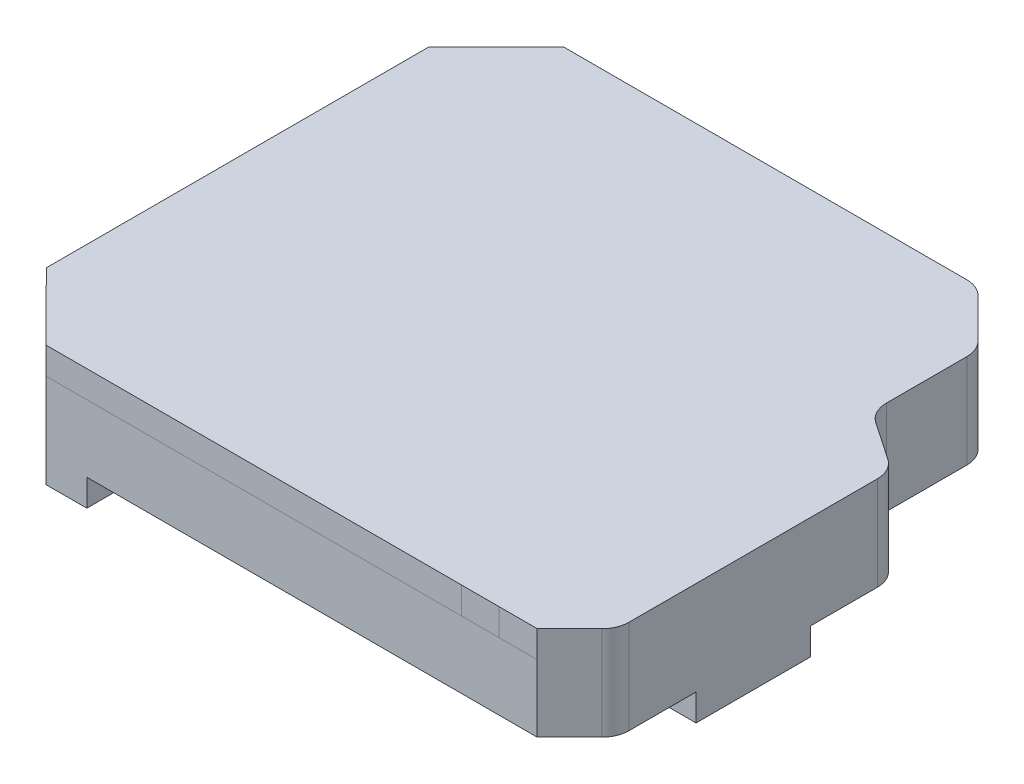
from build123d import *
from OCP.BRepFilletAPI import BRepFilletAPI_MakeChamfer

# Parameters (mm, degrees)
SKETCH1_W               = 41
SKETCH1_H               = 34.5
SKETCH1_W_2             = 35
SKETCH1_H_2             = 28.5
BOSS_EXTRUDE1_DEPTH     = 5
SKETCH2_W               = 35
SKETCH2_H               = 28.5
BOSS_EXTRUDE2_DEPTH     = 1
SKETCH6_W               = 34.5
SKETCH6_H               = 5
CUT_EXTRUDE2_DEPTH      = 3
SKETCH7_W               = 1.6
SKETCH7_H               = 3
SKETCH7_H_2             = 3.078736203
BOSS_EXTRUDE3_DEPTH     = 4
CHAMFER1_SIZE           = 3
SKETCH14_W              = 3.502632447
SKETCH14_H              = 20.452559449
CUT_EXTRUDE6_DEPTH      = 10
BOSS_EXTRUDE5_DEPTH     = 4
BOSS_EXTRUDE7_DEPTH     = 1
SKETCH9_W               = 3.28281374
SKETCH9_H               = 22.420706044
CUT_EXTRUDE3_DEPTH      = 4
BOSS_EXTRUDE4_DEPTH     = 2
SKETCH12_W              = 3.28281374
SKETCH12_H              = 22.420706044
CUT_EXTRUDE4_DEPTH      = 0.003863752
BOSS_EXTRUDE8_DEPTH     = 2
BOSS_EXTRUDE9_DEPTH     = 2
CUT_EXTRUDE7_DEPTH      = 38.864903937
CUT_EXTRUDE7_DEPTH_BACK = 4
CHAMFER2_SIZE           = 3
CHAMFER2_SIZE_2         = 3.001586398
CHAMFER2_SIZE2          = 3
CHAMFER3_SIZE           = 2
BOSS_EXTRUDE10_DEPTH    = 7
CUT_EXTRUDE8_START      = -2
CUT_EXTRUDE8_DEPTH      = 7
CUT_EXTRUDE9_DEPTH      = 7
CUT_EXTRUDE11_START     = 1
CUT_EXTRUDE11_DEPTH     = 10
CUT_EXTRUDE12_DEPTH     = 10
SKETCH30_W              = 2.837179027
SKETCH30_H              = 7
CUT_EXTRUDE13_DEPTH     = 10
BOSS_EXTRUDE11_DEPTH    = 7
CUT_EXTRUDE14_DEPTH     = 7
SKETCH35_W              = 36.645868519
SKETCH35_H              = 38.499838471
CUT_EXTRUDE15_DEPTH     = 2
SKETCH37_W              = 2
SKETCH37_H              = 8.507497338
BOSS_EXTRUDE12_DEPTH    = 2
FILLET2_R               = 2


with BuildPart() as part:
    # Sketch1 → Boss-Extrude1 (new body)
    with BuildSketch(Plane(origin=(0, 0, 0), x_dir=(1, 0, 0), z_dir=(0, 1, 0))):
        with Locations((-14.14154724, 0.334775681)):
            Rectangle(SKETCH1_W, SKETCH1_H)
        with Locations((-14.14154724, 0.334775681)):
            Rectangle(SKETCH1_W_2, SKETCH1_H_2, mode=Mode.SUBTRACT)
    extrude(amount=BOSS_EXTRUDE1_DEPTH)

    # Sketch2 → Boss-Extrude2 (add)
    with BuildSketch(Plane(origin=(0, 0, 0), x_dir=(1, 0, 0), z_dir=(0, 1, 0))):
        with Locations((-14.14154724, 0.334775681)):
            Rectangle(SKETCH2_W, SKETCH2_H)
    extrude(amount=BOSS_EXTRUDE2_DEPTH)

    # Sketch6 → Cut-Extrude2 (cut)
    with BuildSketch(Plane.ZY.offset(34.64154724)):
        with Locations((-0.334775681, 2.5)):
            Rectangle(SKETCH6_W, SKETCH6_H)
    extrude(amount=-CUT_EXTRUDE2_DEPTH, mode=Mode.SUBTRACT)

    # Sketch7 → Boss-Extrude3 (add)
    with BuildSketch(Plane(origin=(0, 1, 0), x_dir=(1, 0, 0), z_dir=(0, 1, 0))):
        with Locations((-30.84154724, 13.084775681)):
            Rectangle(SKETCH7_W, SKETCH7_H)
        with Locations((-30.84154724, -12.375856218)):
            Rectangle(SKETCH7_W, SKETCH7_H_2)
    extrude(amount=BOSS_EXTRUDE3_DEPTH)

    # Chamfer1
    chamfer1_edges = [part.edges().sort_by_distance(p)[0] for p in [
        (-31.64154724, 2.5, -17.584775681),
        (-31.64154724, 2.5, 16.915224319),
        (6.35845276, 2.5, -17.584775681),
        (6.35845276, 2.5, 16.915224319),
    ]]
    chamfer(chamfer1_edges, length=CHAMFER1_SIZE)

    # Sketch14 → Cut-Extrude6 (cut)
    with BuildSketch(Plane(origin=(0, 1, 0), x_dir=(1, 0, 0), z_dir=(0, 1, 0))):
        with Locations((5.109768984, -7.134544415)):
            Rectangle(SKETCH14_W, SKETCH14_H)
    extrude(amount=CUT_EXTRUDE6_DEPTH, mode=Mode.SUBTRACT)

    # Sketch17 → Boss-Extrude5 (add)
    with BuildSketch(Plane(origin=(0, 1, 0), x_dir=(1, 0, 0), z_dir=(0, 1, 0))):
        Polygon((3.35845276, 3.09173531), (7.910000942, 0), (7.910000942, -13.915224319), (3.35845276, -13.915224319), (3.35845276, -16.915224319), (10.910000942, -16.915224319), (10.910000942, 3.419581668), (3.35845276, 8.549130391), align=None)
    extrude(amount=BOSS_EXTRUDE5_DEPTH)

    # Sketch19 → Boss-Extrude7 (add)
    with BuildSketch(Plane.XZ):
        Polygon((3.35845276, 16.915224319), (10.910000942, 16.915224319), (10.910000942, -3.419581668), (6.35845276, -6.511316978), (6.35845276, 13.915224319), align=None)
    extrude(amount=-BOSS_EXTRUDE7_DEPTH)

    # Sketch9 → Cut-Extrude3 (cut)
    with BuildSketch(Plane(origin=(0, 1, 0), x_dir=(1, 0, 0), z_dir=(0, 1, 0))):
        with Locations((-30.00014037, 0.374422659)):
            Rectangle(SKETCH9_W, SKETCH9_H)
    extrude(amount=-CUT_EXTRUDE3_DEPTH, mode=Mode.SUBTRACT)

    # Sketch11 → Boss-Extrude4 (add)
    with BuildSketch(Plane.XZ):
        Polygon((-26.665503706, 18.915224319), (-31.64154724, 13.915224319), (-31.64154724, -14.584775681), (-26.629189212, -19.584775681), (4.233785533, -19.584775681), (8.35845276, -15.460108453), (8.35845276, 14.743651444), (4.263960312, 18.915224319), align=None)
    extrude(amount=BOSS_EXTRUDE4_DEPTH)

    # Sketch12 → Cut-Extrude4 (cut)
    with BuildSketch(Plane(origin=(0, 0, 0), x_dir=(1, 0, 0), z_dir=(0, 1, 0))):
        with Locations((-30.00014037, 0.374422659)):
            Rectangle(SKETCH12_W, SKETCH12_H)
    extrude(amount=-CUT_EXTRUDE4_DEPTH, mode=Mode.SUBTRACT)

    # Sketch20 → Boss-Extrude8 (add)
    with BuildSketch(Plane.XZ):
        Polygon((6.227005221, 16.915224319), (10.910000942, 16.915224319), (10.910000942, -3.419581668), (8.35845276, -5.152774704), (8.35845276, 14.743651444), align=None)
    extrude(amount=BOSS_EXTRUDE8_DEPTH)

    # Sketch21 → Boss-Extrude9 (add)
    with BuildSketch(Plane(origin=(0, 0, 0), x_dir=(1, 0, 0), z_dir=(0, 1, 0))):
        Polygon((8.35845276, 7.570549944), (8.35845276, 5.152774704), (10.90766939, 3.421165424), (10.90766939, -16.912751148), (6.227005221, -16.915224319), (4.263960312, -18.915224319), (7.06681334, -18.91478086), (12.90766939, -18.911694666), (12.90766939, 4.480398389), align=None)
    extrude(amount=-BOSS_EXTRUDE9_DEPTH)

    # Sketch23 → Cut-Extrude7 (cut, two sides)
    with BuildSketch(Plane(origin=(0, 5, 0), x_dir=(1, 0, 0), z_dir=(0, 1, 0))) as cut_extrude7_sk:
        Polygon((7.910000942, 0), (7.910000942, 1.828776855), (3.35845276, 4.913740582), (3.35845276, 3.09173531), align=None)
    extrude(amount=CUT_EXTRUDE7_DEPTH, mode=Mode.SUBTRACT)
    extrude(cut_extrude7_sk.sketch, amount=-CUT_EXTRUDE7_DEPTH_BACK, mode=Mode.SUBTRACT)

    # Chamfer2: one chamfer whose edges measure the first distance from different faces: ONE call of the kernel's chamfer builder (chamfer() names one face for all edges)
    chamfer2_edges_1 = [part.edges().sort_by_distance(p)[0] for p in [
        (10.910000942, 2.5, 16.915224319),
    ]]
    chamfer2_edges_2 = [part.edges().sort_by_distance(p)[0] for p in [
        (12.90766939, -1, 18.911694666),
    ]]
    chamfer2_side_2 = [part.faces().sort_by_distance(p)[0] for p in [
        (9.987241365, -1, 18.913237763),
    ]]
    chamfer2 = BRepFilletAPI_MakeChamfer(part.part.solid().wrapped)
    for e in chamfer2_edges_1:
        chamfer2.Add(CHAMFER2_SIZE, e.wrapped)
    for e in chamfer2_edges_2:
        chamfer2.Add(CHAMFER2_SIZE_2, CHAMFER2_SIZE2, e.wrapped, chamfer2_side_2[0].wrapped)  # the first distance lies on this face
    add(Compound.cast(chamfer2.Shape()), mode=Mode.REPLACE)

    # Chamfer3
    chamfer3_edges = [part.edges().sort_by_distance(p)[0] for p in [
        (7.910000942, 3, 13.915224319),
    ]]
    chamfer(chamfer3_edges, length=CHAMFER3_SIZE)

    # Sketch25 → Boss-Extrude10 (add)
    with BuildSketch(Plane(origin=(0, 0, 0), x_dir=(1, 0, 0), z_dir=(0, 1, 0))):
        Polygon((-28.64154724, 17.584775681), (-26.629189212, 19.584775681), (4.233785533, 19.584775681), (8.35845276, 15.460108453), (8.35845276, 7.570549944), (12.90766939, 4.480398389), (12.90766939, -15.911694666), (9.906083411, -18.913280645), (-26.665503706, -18.915224319), (-28.64154724, -16.915224319), (7.910000942, -16.915224319), (10.910000942, -13.915224319), (10.910000942, 3.419581668), (6.35845276, 6.511316978), (6.35845276, 14.584775681), (3.35845276, 17.584775681), align=None)
    extrude(amount=BOSS_EXTRUDE10_DEPTH)

    # Sketch26 → Cut-Extrude8 (cut)
    with BuildSketch(Plane.XZ.offset(2).offset(CUT_EXTRUDE8_START)):
        Polygon((10.90766939, -3.421165424), (10.90766939, 15.083267541), (9.077218609, 16.913718322), (7.066126742, 16.914780944), (4.263802095, 16.915224319), (-25.834261771, 16.915224319), (-29.64154724, 13.089609206), (-29.64154724, -13.754902141), (-25.802207763, -17.584775681), (3.405358408, -17.584775681), (6.35845276, -14.631681329), (6.35845276, -6.511316978), align=None)
    extrude(amount=-CUT_EXTRUDE8_DEPTH, mode=Mode.SUBTRACT)

    # Sketch27 → Cut-Extrude9 (cut)
    with BuildSketch(Plane(origin=(0, 0, 0), x_dir=(1, 0, 0), z_dir=(0, 1, 0))):
        Polygon((-25.802207763, 17.584775681), (-28.64154724, 17.584775681), (-31.64154724, 14.584775681), (-31.64154724, 11.584775681), (-29.64154724, 11.584775681), (-29.64154724, 13.754902141), align=None)
        Polygon((-29.64154724, -10.835930363), (-29.64154724, -13.089609206), (-25.834261771, -16.915224319), (-28.64154724, -16.915224319), (-31.64154724, -13.915224319), (-31.64154724, -10.835930363), align=None)
    extrude(amount=CUT_EXTRUDE9_DEPTH, mode=Mode.SUBTRACT)

    # Sketch28 → Cut-Extrude11 (cut)
    with BuildSketch(Plane(origin=(0, -0.003863752, 0), x_dir=(1, 0, 0), z_dir=(0, 1, 0)).offset(CUT_EXTRUDE11_START)):
        Polygon((-31.64154724, -13.915224319), (-26.665503706, -18.915224319), (9.906083411, -18.913280645), (12.90766939, -15.911694666), (12.90766939, 4.480398389), (8.35845276, 7.570549944), (8.35845276, 15.460108453), (4.233785533, 19.584775681), (-26.629189212, 19.584775681), (-31.64154724, 14.584775681), align=None)
    extrude(amount=CUT_EXTRUDE11_DEPTH, mode=Mode.SUBTRACT)

    # Sketch29 → Cut-Extrude12 (cut)
    with BuildSketch(Plane(origin=(0, -0.003863752, 0), x_dir=(1, 0, 0), z_dir=(0, 1, 0))):
        Polygon((-31.64154724, 14.584775681), (-26.629189212, 19.584775681), (4.233785533, 19.584775681), (8.35845276, 15.460108453), (8.35845276, 7.570549944), (12.90766939, 4.480398389), (12.90766939, -15.911694666), (9.906083411, -18.913280645), (-26.665503706, -18.915224319), (-31.64154724, -13.915224319), align=None)
    extrude(amount=CUT_EXTRUDE12_DEPTH, mode=Mode.SUBTRACT)


with BuildPart() as cut_extrude12_piece_1:
    # of the separate pieces the step leaves, piece 1, a body of its own (cut_extrude12_pieces)
    add(part.part.solids().sort_by_distance((-31.64154724, -0.003863752, -14.584775681))[0])

    # Sketch31 → Boss-Extrude11 (add)
    with BuildSketch(Plane.XZ.offset(2)):
        Polygon((6.35845276, -6.511316978), (10.90766939, -3.421165424), (10.90766939, 15.083267541), (9.077218609, 16.913718322), (7.066126742, 16.914780944), (4.263802095, 16.915224319), (-25.834261771, 16.915224319), (-29.64154724, 13.089609206), (-31.64154724, 13.915224319), (-26.665503706, 18.915224319), (9.906083411, 18.913280645), (12.90766939, 15.911694666), (12.90766939, -4.480398389), (8.35845276, -7.570549944), (8.35845276, -15.460108453), (4.233785533, -19.584775681), (-26.629189212, -19.584775681), (-31.64154724, -14.584775681), (-29.64154724, -13.754902141), (-25.802207763, -17.584775681), (3.405358408, -17.584775681), (6.35845276, -14.631681329), align=None)
    extrude(amount=BOSS_EXTRUDE11_DEPTH)

    # Sketch32 → Cut-Extrude14 (cut)
    with BuildSketch(Plane.XZ.offset(2)):
        Polygon((-25.834261771, 16.915224319), (-25.802207763, -17.584775681), (-29.64154724, -13.754902141), (-31.64154724, -14.584775681), (-31.64154724, 13.915224319), (-29.64154724, 13.089609206), align=None)
        Polygon((-29.64154724, 13.089609206), (-25.834261771, 16.915224319), (-36.844784184, 16.915224319), (-37.593826415, -17.584775681), (-25.802207763, -17.584775681), (-29.64154724, -13.754902141), (-31.64154724, -14.584775681), (-31.64154724, 13.915224319), align=None)
    extrude(amount=CUT_EXTRUDE14_DEPTH, mode=Mode.SUBTRACT)

    # Sketch35 → Cut-Extrude15 (cut)
    with BuildSketch(Plane.XZ.offset(9)):
        with Locations((-5.303289834, -0.334856445)):
            Rectangle(SKETCH35_W, SKETCH35_H)
    extrude(amount=-CUT_EXTRUDE15_DEPTH, mode=Mode.SUBTRACT)

    # Sketch37 → Boss-Extrude12 (add)
    with BuildSketch(Plane.XZ.offset(7)):
        with Locations((11.90766939, 5.829727419)):
            Rectangle(SKETCH37_W, SKETCH37_H)
    extrude(amount=BOSS_EXTRUDE12_DEPTH)

    # Fillet2
    fillet2_edges = [cut_extrude12_piece_1.edges().sort_by_distance(p)[0] for p in [
        (12.90766939, -3.501931876, -4.480398389),
        (8.35845276, -3.501931876, -7.570549944),
        (4.233785533, -3.501931876, -19.584775681),
        (8.35845276, -3.501931876, -15.460108453),
        (12.90766939, -3.501931876, 15.911694666),
    ]]
    fillet(fillet2_edges, radius=FILLET2_R)


with BuildPart() as cut_extrude12_piece_2:
    # of the separate pieces the step leaves, piece 2, a body of its own (cut_extrude12_pieces)
    add(part.part.solids().sort_by_distance((-28.634132423, 0, -17.584775681))[0])

    # Sketch30 → Cut-Extrude13 (cut)
    with BuildSketch(Plane(origin=(-23.02477977, 0, -23.167050199), x_dir=(-0.7092812996014342, 0, 0.7049255549600261), z_dir=(-0.7049255549600261, 0, -0.7092812996014342))):
        with Locations((6.500366579, 3.5)):
            Rectangle(SKETCH30_W, SKETCH30_H)
    extrude(amount=-CUT_EXTRUDE13_DEPTH, mode=Mode.SUBTRACT)


solid = cut_extrude12_piece_1.part
